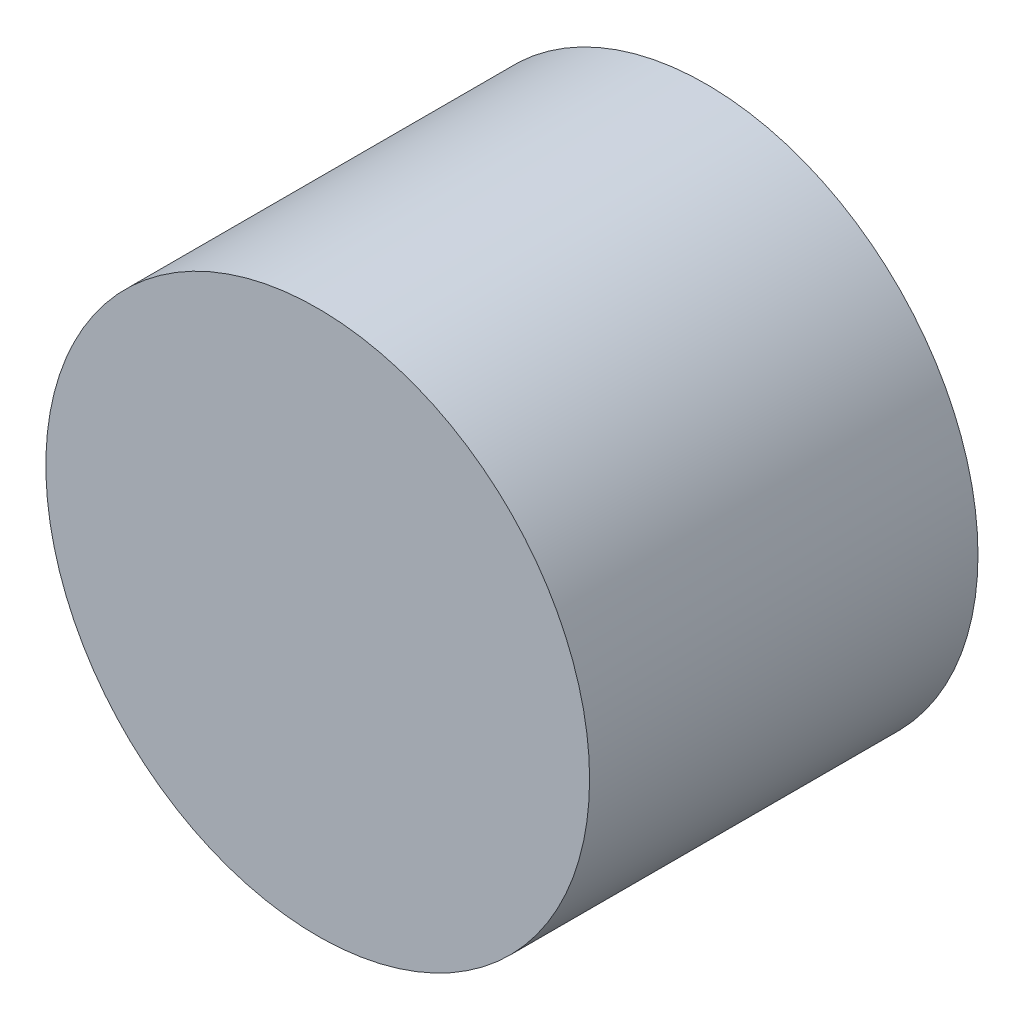
from build123d import *

# Parameters (mm, degrees)
SKETCH1_R           = 35.56
BOSS_EXTRUDE1_DEPTH = 50.8


with BuildPart() as part:
    # Sketch1 → Boss-Extrude1 (new body)
    with BuildSketch(Plane(origin=(0, 0, 0), x_dir=(0, 1, 0), z_dir=(0, 0, 1))):
        with Locations((0, 0.351224747)):
            Circle(SKETCH1_R)
    extrude(amount=BOSS_EXTRUDE1_DEPTH)


solid = part.part
